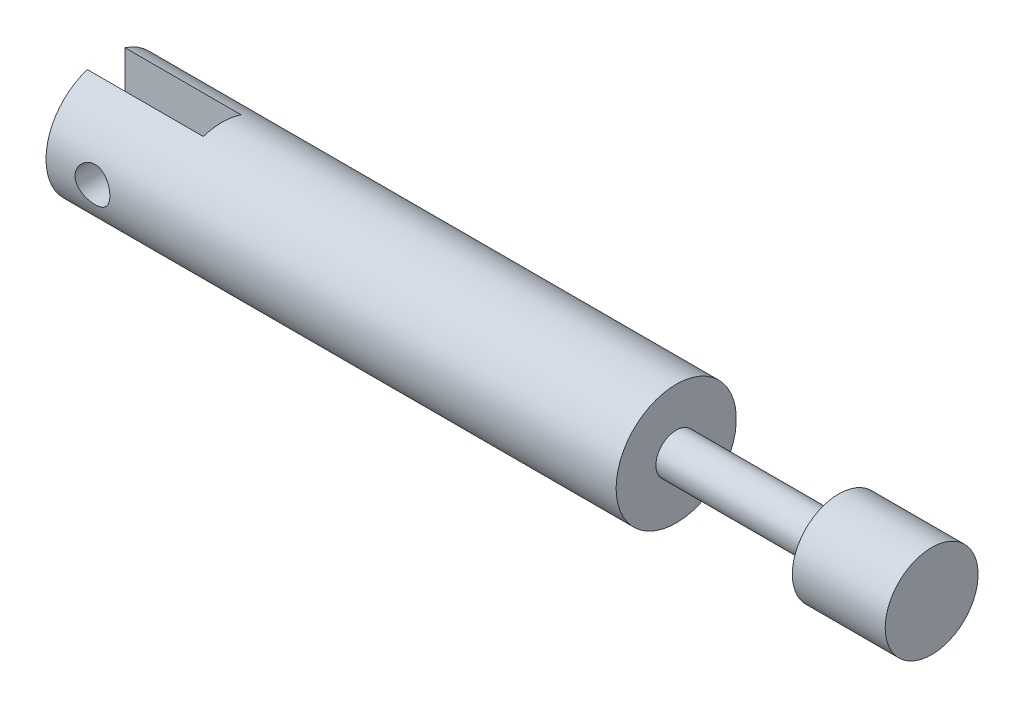
from build123d import *

# Parameters (mm, degrees)
SKETCH1_W          = 14
SKETCH1_H          = 1.75
CUT_EXTRUDE1_REACH = 12.35
SKETCH2_R          = 1.5
SKETCH3_W          = 3.25
SKETCH3_H          = 10.35
CUT_EXTRUDE2_DEPTH = 10


with BuildPart() as part:
    # Sketch1 → Revolve1 (revolve)
    with BuildSketch(Plane.XY):
        Polygon((0, 5.175), (0, 0), (49.1, 0), (49.1, 1.75), (49.1, 5.175), align=None)
        with Locations((56.1, 0.875)):
            Rectangle(SKETCH1_W, SKETCH1_H)
        Polygon((63.1, 1.75), (63.1, 0), (71.1, 0), (71.1, 4), (63.1, 4), align=None)
    revolve(axis=Axis((0, 0, 0), (1, 0, 0)))

    # Sketch2 → Cut-Extrude1 (cut, up to next)
    with BuildSketch(Plane.XY.offset(5.175), mode=Mode.PRIVATE) as cut_extrude1_sk1:
        with Locations((4, 0)):
            Circle(SKETCH2_R)
    cut_extrude1_tool1 = extrude(cut_extrude1_sk1.sketch, amount=-CUT_EXTRUDE1_REACH, mode=Mode.PRIVATE) & part.part
    add(cut_extrude1_tool1.solids().sort_by_distance((4, 0, 5.175))[0], mode=Mode.SUBTRACT)

    # Sketch3 → Cut-Extrude2 (cut)
    with BuildSketch(Plane.ZY):
        Rectangle(SKETCH3_W, SKETCH3_H)
    extrude(amount=-CUT_EXTRUDE2_DEPTH, mode=Mode.SUBTRACT)


solid = part.part
